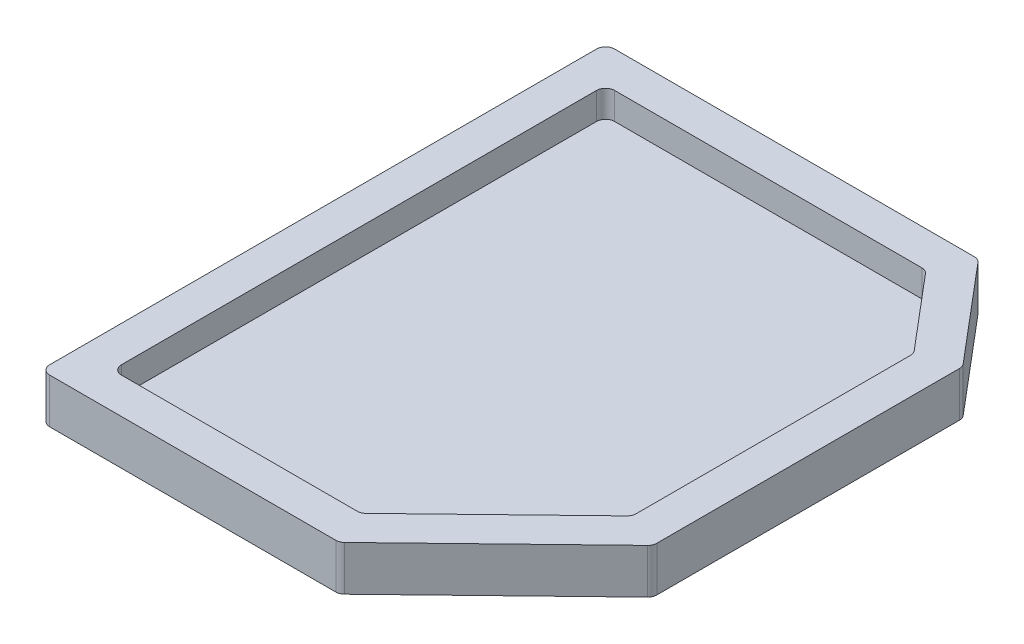
from build123d import *

# Parameters (mm, degrees)
BOSS_EXTRUDE1_DEPTH = 5
BOSS_EXTRUDE2_DEPTH = 2
FILLET1_R           = 1


with BuildPart() as part:
    # Sketch1 → Boss-Extrude1 (new body)
    with BuildSketch(Plane(origin=(0, 0, 0), x_dir=(1, 0, 0), z_dir=(0, 1, 0))):
        Polygon((-4.5, -4.5), (-4.5, 58.5), (37.089540976, 58.5), (46.597851618, 47.242502808), (46.597851618, 12.6877701), (28.819604063, -4.5), align=None)
        Polygon((-0.5, -0.5), (-0.5, 54.5), (35.23217122, 54.5), (42.597851618, 45.779299812), (42.597851618, 14.384329511), (27.202178229, -0.5), align=None, mode=Mode.SUBTRACT)
    extrude(amount=BOSS_EXTRUDE1_DEPTH)

    # Sketch1_2 → Boss-Extrude2 (add)
    with BuildSketch(Plane(origin=(0, 0, 0), x_dir=(1, 0, 0), z_dir=(0, 1, 0))):
        Polygon((27.202178229, -0.5), (-0.5, -0.5), (-0.5, 54.5), (35.23217122, 54.5), (42.597851618, 45.779299812), (42.597851618, 14.384329511), align=None)
    extrude(amount=BOSS_EXTRUDE2_DEPTH)

    # Fillet1
    fillet1_edges = [part.edges().sort_by_distance(p)[0] for p in [
        (-4.5, 2.5, 4.5),
        (-4.5, 2.5, -58.5),
        (37.089540976, 2.5, -58.5),
        (46.597851618, 2.5, -47.242502808),
        (46.597851618, 2.5, -12.6877701),
        (28.819604063, 2.5, 4.5),
        (-0.5, 3.5, 0.5),
        (27.202178229, 3.5, 0.5),
        (42.597851618, 3.5, -14.384329511),
        (42.597851618, 3.5, -45.779299812),
        (35.23217122, 3.5, -54.5),
        (-0.5, 3.5, -54.5),
    ]]
    fillet(fillet1_edges, radius=FILLET1_R)


solid = part.part
